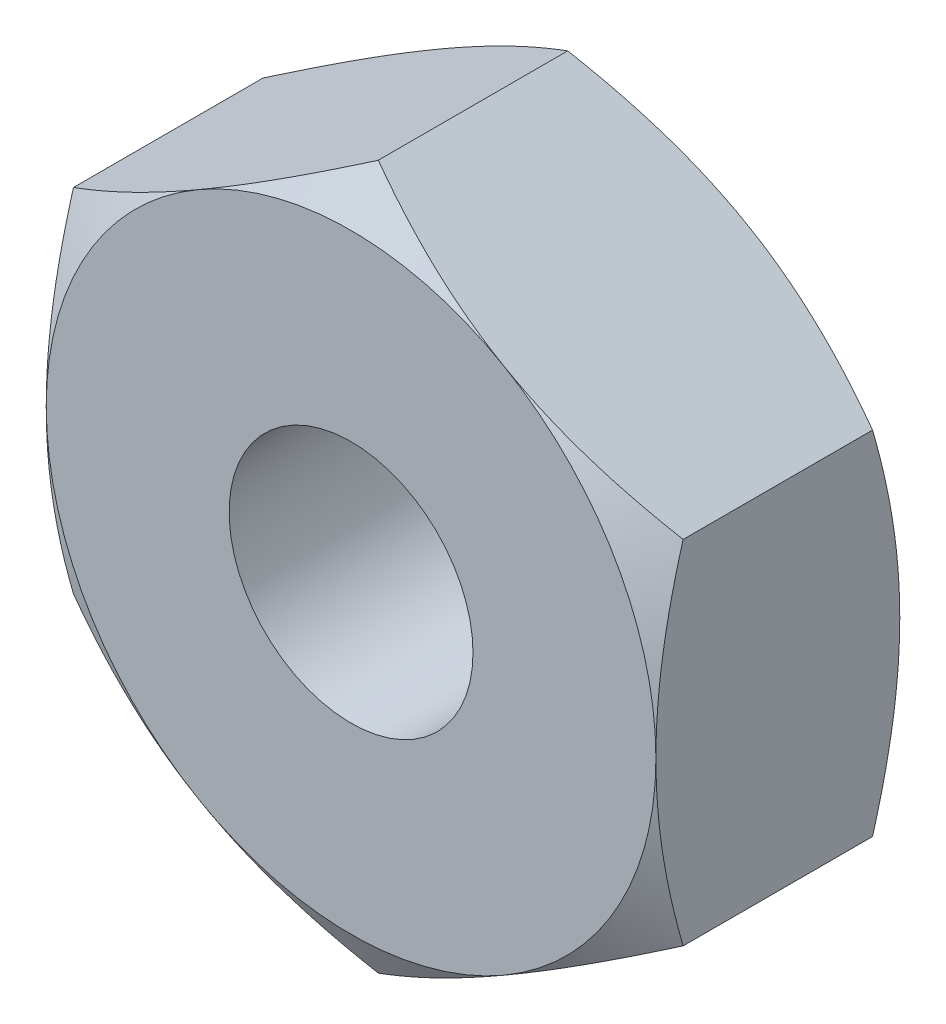
from build123d import *

# Parameters (mm, degrees)
SKETCH1_R           = 1
BOSS_EXTRUDE1_DEPTH = 2
SKETCH2_OUTSIDE_W   = 15.508
SKETCH2_OUTSIDE_H   = 16.282
SKETCH2_OUTSIDE_R   = 2.5
CUT_EXTRUDE1_DEPTH  = 2
CUT_EXTRUDE1_TAPER  = 60
SKETCH3_OUTSIDE_W   = 15.508
SKETCH3_OUTSIDE_H   = 16.282
SKETCH3_OUTSIDE_R   = 2.5
CUT_EXTRUDE2_DEPTH  = 2
CUT_EXTRUDE2_TAPER  = 60


with BuildPart() as part:
    # Sketch1 → Boss-Extrude1 (new body)
    with BuildSketch(Plane.XY):
        Polygon((0, -2.886751346), (2.5, -1.443375673), (2.5, 1.443375673), (0, 2.886751346), (-2.5, 1.443375673), (-2.5, -1.443375673), align=None)
        Circle(SKETCH1_R, mode=Mode.SUBTRACT)
    extrude(amount=BOSS_EXTRUDE1_DEPTH)

    # Sketch2 outside → Cut-Extrude1 (cut)
    with BuildSketch(Plane.XY.offset(2)):
        Rectangle(SKETCH2_OUTSIDE_W, SKETCH2_OUTSIDE_H)
        Circle(SKETCH2_OUTSIDE_R, mode=Mode.SUBTRACT)
    extrude(amount=-CUT_EXTRUDE1_DEPTH, taper=CUT_EXTRUDE1_TAPER, mode=Mode.SUBTRACT)

    # Sketch3 outside → Cut-Extrude2 (cut)
    with BuildSketch(Plane(origin=(0, 0, 0), x_dir=(-1, 0, 0), z_dir=(0, 0, -1))):
        Rectangle(SKETCH3_OUTSIDE_W, SKETCH3_OUTSIDE_H)
        Circle(SKETCH3_OUTSIDE_R, mode=Mode.SUBTRACT)
    extrude(amount=-CUT_EXTRUDE2_DEPTH, taper=CUT_EXTRUDE2_TAPER, mode=Mode.SUBTRACT)


solid = part.part
